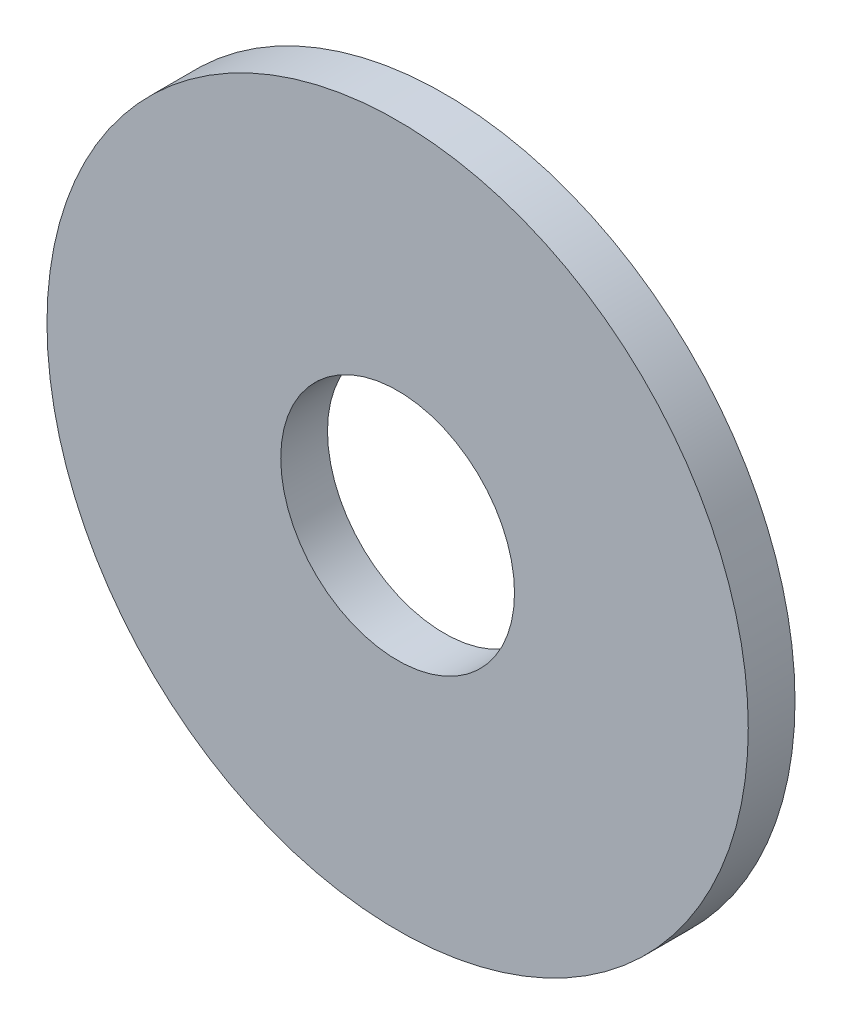
from build123d import *

# Parameters (mm, degrees)
SKETCH1_R           = 7.5
SKETCH1_R_2         = 2.5
BOSS_EXTRUDE1_DEPTH = 1


with BuildPart() as part:
    # Sketch1 → Boss-Extrude1 (new body)
    with BuildSketch(Plane.XY):
        Circle(SKETCH1_R)
        Circle(SKETCH1_R_2, mode=Mode.SUBTRACT)
    extrude(amount=BOSS_EXTRUDE1_DEPTH)


solid = part.part
